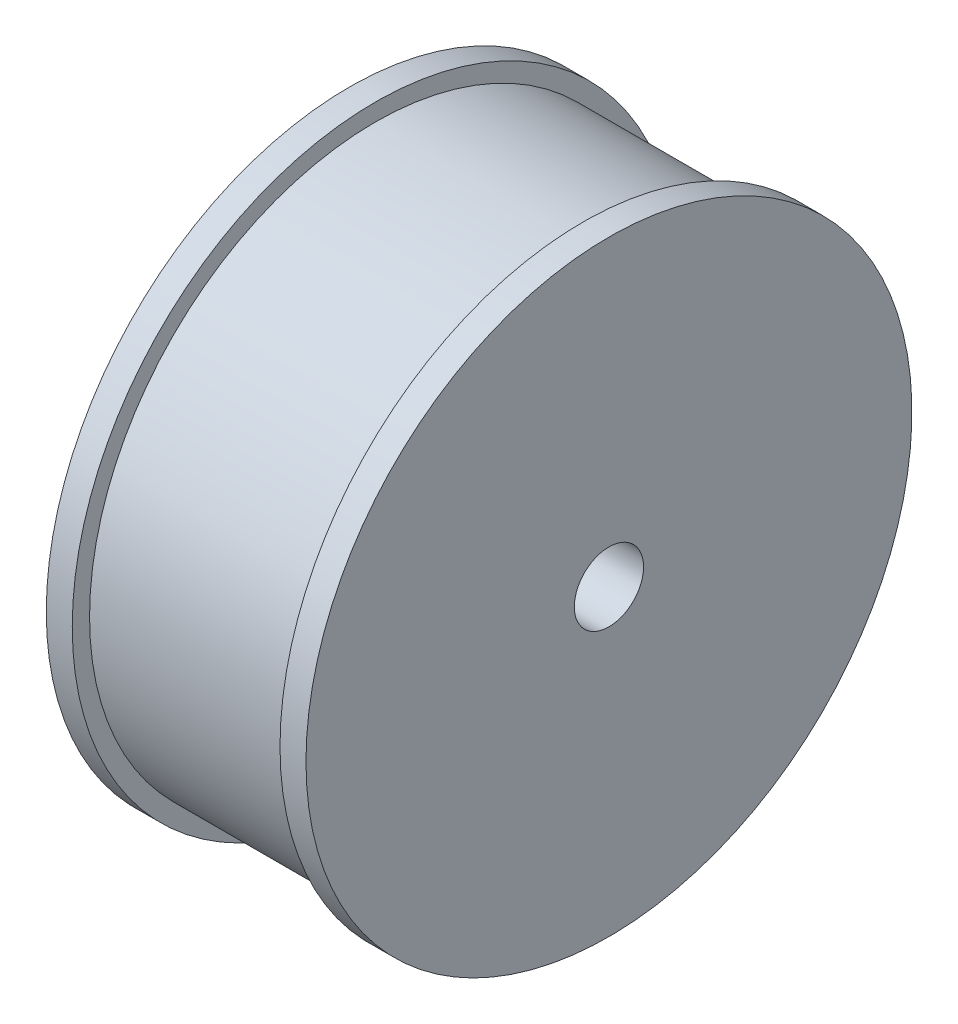
from build123d import *

# Parameters (mm, degrees)
SKETCH4_R           = 10
BOSS_EXTRUDE2_DEPTH = 8
SKETCH6_R           = 4
CUT_EXTRUDE1_DEPTH  = 38


with BuildPart() as part:
    # Sketch1 → Revolve1 (revolve)
    with BuildSketch(Plane.XY):
        Polygon((12, 35), (15, 35), (15, 0), (-15, 0), (-15, 35), (-12, 35), (-12, 33), (12, 33), align=None)
    revolve(axis=Axis((-15, 0, 0), (1, 0, 0)))

    # Sketch4 → Boss-Extrude2 (add)
    with BuildSketch(Plane.ZY.offset(15)):
        Circle(SKETCH4_R)
    extrude(amount=BOSS_EXTRUDE2_DEPTH)

    # Sketch6 → Cut-Extrude1 (cut)
    with BuildSketch(Plane(origin=(15, 0, 0), x_dir=(0, 0, -1), z_dir=(1, 0, 0))):
        Circle(SKETCH6_R)
    extrude(amount=-CUT_EXTRUDE1_DEPTH, mode=Mode.SUBTRACT)


solid = part.part
